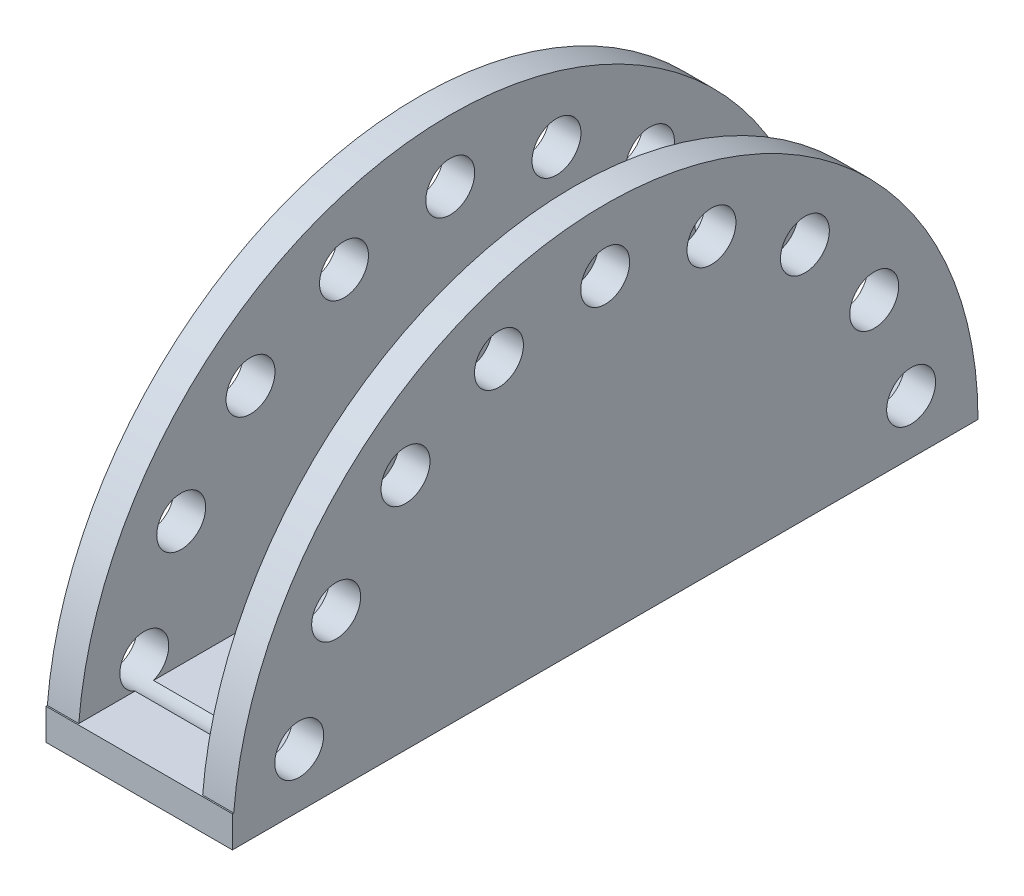
from build123d import *

# Parameters (mm, degrees)
BOSS_EXTRUDE1_DEPTH = 38.1
SKETCH2_W           = 25.3238
SKETCH2_H           = 160.690428667
CUT_EXTRUDE1_DEPTH  = 77.2
SKETCH3_W           = 152.130858671
SKETCH3_H           = 6.398804689
BOSS_EXTRUDE2_DEPTH = 38.1
SKETCH4_R           = 5.0000027
CUT_EXTRUDE2_DEPTH  = 39.1


with BuildPart() as part:
    # Sketch1 → Boss-Extrude1 (new body)
    with BuildSketch(Plane(origin=(0, 0, 0), x_dir=(0, 0, -1), z_dir=(1, 0, 0))):
        with BuildLine():
            Line((-76.2, 0), (76.2, 0))
            ThreePointArc((76.2, 0), (0, 76.2), (-76.2, 0))
        make_face()
    extrude(amount=BOSS_EXTRUDE1_DEPTH)

    # Sketch2 → Cut-Extrude1 (cut, through all)
    with BuildSketch(Plane.XZ):
        with Locations((19.0881, -0.10655864)):
            Rectangle(SKETCH2_W, SKETCH2_H)
    extrude(amount=-CUT_EXTRUDE1_DEPTH, mode=Mode.SUBTRACT)

    # Sketch3 → Boss-Extrude2 (add)
    with BuildSketch(Plane(origin=(38.1, 0, 0), x_dir=(0, 0, -1), z_dir=(1, 0, 0))):
        with Locations((-0.134570664, 3.199402345)):
            Rectangle(SKETCH3_W, SKETCH3_H)
    extrude(amount=-BOSS_EXTRUDE2_DEPTH)

    # Sketch4 → Cut-Extrude2 (cut, through all)
    with BuildSketch(Plane(origin=(38.1, 0, 0), x_dir=(0, 0, -1), z_dir=(1, 0, 0))):
        with Locations((0, 63.5)):
            Circle(SKETCH4_R)
        with Locations((21.718279101, 59.67048142)):
            Circle(SKETCH4_R)
        with Locations((40.817013215, 48.643822138)):
            Circle(SKETCH4_R)
        with Locations((54.99261314, 31.75)):
            Circle(SKETCH4_R)
        with Locations((62.535292316, 11.026659282)):
            Circle(SKETCH4_R)
        with Locations((-62.535292316, 11.026659282)):
            Circle(SKETCH4_R)
        with Locations((-54.99261314, 31.75)):
            Circle(SKETCH4_R)
        with Locations((-40.817013215, 48.643822138)):
            Circle(SKETCH4_R)
        with Locations((-21.718279101, 59.67048142)):
            Circle(SKETCH4_R)
    extrude(amount=-CUT_EXTRUDE2_DEPTH, mode=Mode.SUBTRACT)


solid = part.part
